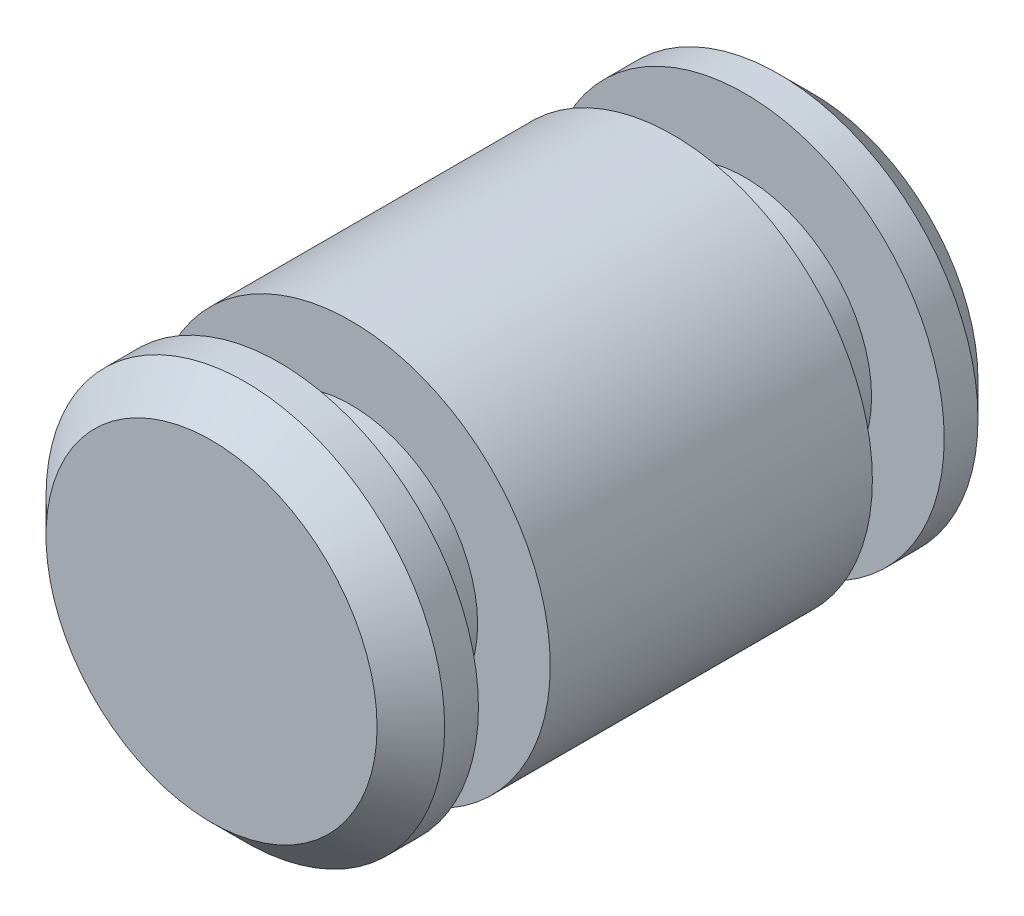
from build123d import *

# Parameters (mm, degrees)
SKETCH1_R           = 1.4986
BOSS_EXTRUDE1_DEPTH = 2.2590125
SKETCH2_W           = 0.540004
SKETCH2_H           = 0.5461
CHAMFER1_SIZE       = 0.254


with BuildPart() as part:
    # Sketch1 → Boss-Extrude1 (new body, symmetric)
    with BuildSketch(Plane.XY):
        Circle(SKETCH1_R)
    extrude(amount=BOSS_EXTRUDE1_DEPTH, both=True)

    # Sketch2 → Cut-Revolve1 (revolve, cut)
    with BuildSketch(Plane(origin=(0, 0, 0), x_dir=(0, 0, -1), z_dir=(1, 0, 0))):
        with Locations((-1.4810105, -1.22555)):
            Rectangle(SKETCH2_W, SKETCH2_H)
        with Locations((1.4810105, -1.22555)):
            Rectangle(SKETCH2_W, SKETCH2_H)
    revolve(axis=Axis((0, 0, 8.828032455), (0, 0, -1)), mode=Mode.SUBTRACT)

    # Chamfer1
    chamfer1_edges = [part.edges().sort_by_distance(p)[0] for p in [
        (-1.4986, 0, -2.2590125),
        (-1.4986, 0, 2.2590125),
    ]]
    chamfer(chamfer1_edges, length=CHAMFER1_SIZE)


solid = part.part
